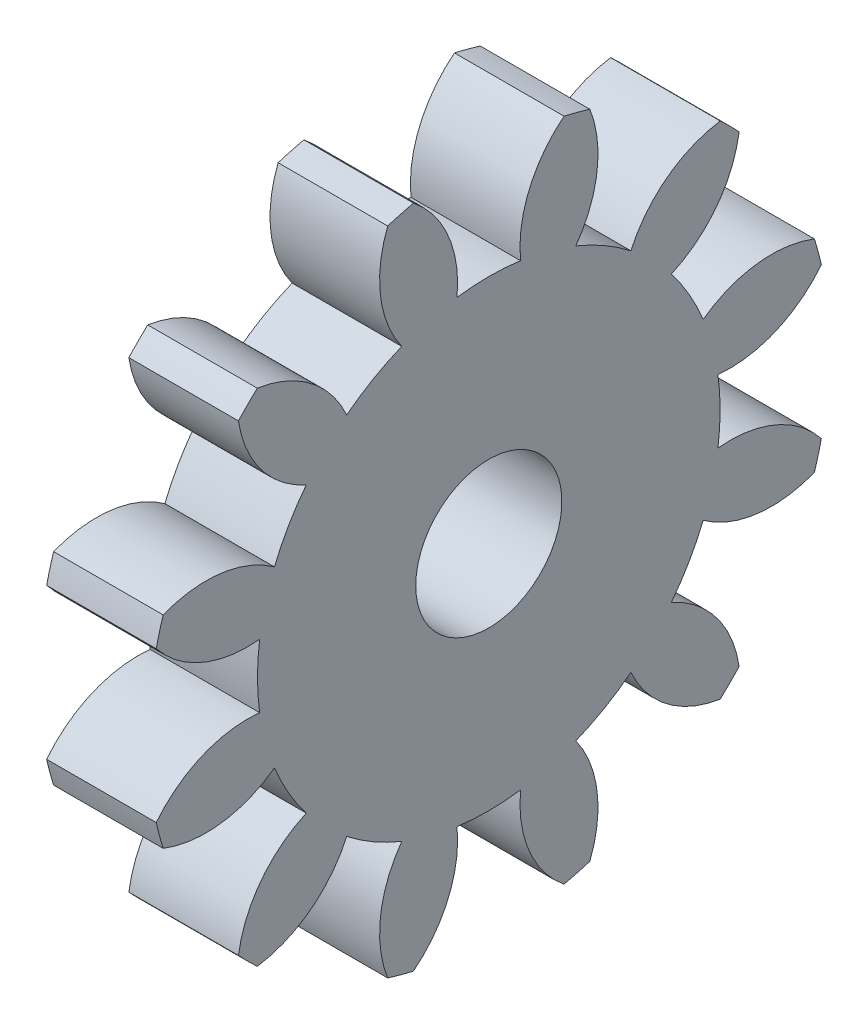
from build123d import *

# Parameters (mm, degrees)
BASPROSKE_W     = 4.7625
BASPROSKE_H     = 14.816666667
TOOTHCUT_DEPTH  = 22.488337034
TEETHCUTS_COUNT = 12
TEETHCUTS_ANGLE = 330
BORSKE_R        = 3.175
BORE_DEPTH      = 50.8000508


with BuildPart() as part:
    # BasProSke → Base-Revolve (revolve)
    with BuildSketch(Plane(origin=(0, 0, 0), x_dir=(1, 0, 0), z_dir=(0, 1, 0)), mode=Mode.PRIVATE) as base_revolve_sk:
        with Locations((2.38125, 7.408333334)):
            Rectangle(BASPROSKE_W, BASPROSKE_H)
    revolve(base_revolve_sk.sketch.rotate(Axis((-10, 0, 0), (1, 0, 0)), 180), axis=Axis((-10, 0, 0), (1, 0, 0)))

    # TooCutSke → ToothCut (cut, through all)
    with BuildSketch(Plane(origin=(0, 0, 0), x_dir=(0, 0, -1), z_dir=(1, 0, 0))):
        with BuildLine():
            ThreePointArc((1.381843105, 9.957471618), (0, 10.052896667), (-1.381843105, 9.957471618))
            ThreePointArc((-1.381843105, 9.957471618), (-1.758547944, 12.460702813), (-3.296530556, 14.471345108))
            ThreePointArc((-3.296530556, 14.471345108), (0, 14.842066667), (3.296530556, 14.471345108))
            ThreePointArc((3.296530556, 14.471345108), (1.758547944, 12.460702813), (1.381843105, 9.957471618))
        make_face()
    toothcut = extrude(amount=TOOTHCUT_DEPTH, mode=Mode.SUBTRACT)

    # TeethCuts: ToothCut ×12 about axis
    teethcuts_axis = Axis((-10, 0, 0), (1, 0, 0))
    for i in range(1, TEETHCUTS_COUNT):
        add(toothcut.rotate(teethcuts_axis, i * TEETHCUTS_ANGLE / (TEETHCUTS_COUNT - 1)), mode=Mode.SUBTRACT)

    # BorSke → Bore (cut, symmetric)
    with BuildSketch(Plane(origin=(0, 0, 0), x_dir=(0, 0, -1), z_dir=(1, 0, 0))):
        with Locations(Location((0, 0, 0), (0, 0, 180))):
            Circle(BORSKE_R)
    extrude(amount=BORE_DEPTH, both=True, mode=Mode.SUBTRACT)


solid = part.part
